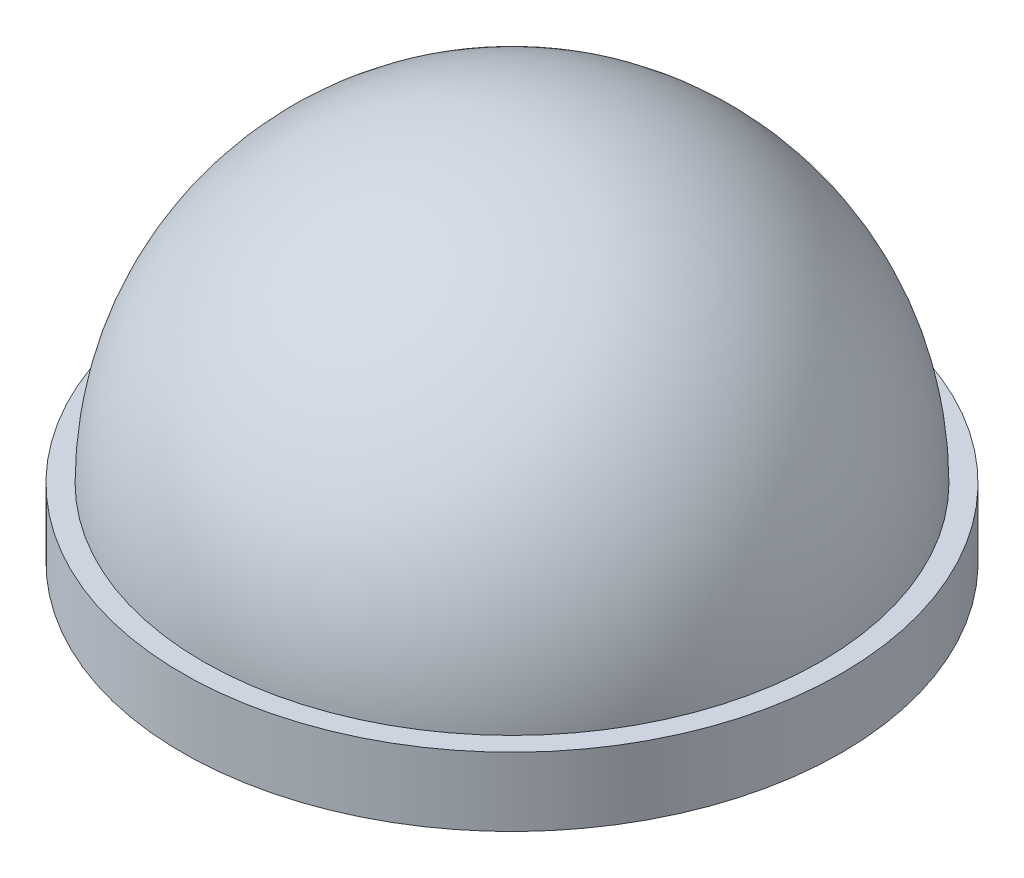
from build123d import *


with BuildPart() as part:
    # Croquis1 → Revolución1 (revolve)
    with BuildSketch(Plane.XY):
        with BuildLine():
            Line((0, 0), (-4.8, 0))
            Line((-4.8, 0), (-4.8, 1))
            Line((-4.8, 1), (-4.5, 1))
            ThreePointArc((-4.5, 1), (-3.181980515, 4.181980515), (0, 5.5))
            Line((0, 5.5), (0, 0))
        make_face()
    revolve(axis=Axis((0, 5.5, 0), (0, -1, 0)))


solid = part.part
